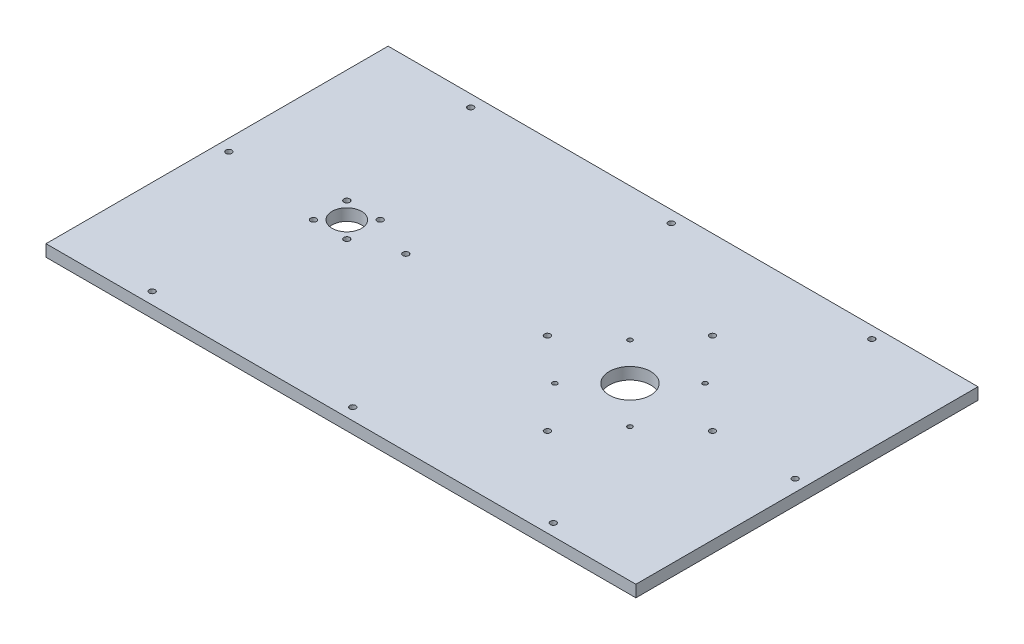
from build123d import *

# Parameters (mm, degrees)
SKETCH1_W           = 500
SKETCH1_H           = 290
SKETCH1_R           = 2.5
SKETCH1_R_2         = 17.5
SKETCH1_R_3         = 12.5
SKETCH1_R_4         = 2
BOSS_EXTRUDE1_DEPTH = 10


with BuildPart() as part:
    # Sketch1 → Boss-Extrude1 (new body)
    with BuildSketch(Plane(origin=(0, 0, 0), x_dir=(1, 0, 0), z_dir=(0, 1, 0))):
        Rectangle(SKETCH1_W, SKETCH1_H)
        with Locations((-240, 0)):
            Circle(SKETCH1_R, mode=Mode.SUBTRACT)
        with Locations((-90, 0)):
            Circle(SKETCH1_R, mode=Mode.SUBTRACT)
        with Locations((-170, -135)):
            Circle(SKETCH1_R, mode=Mode.SUBTRACT)
        with Locations((-170, 135)):
            Circle(SKETCH1_R, mode=Mode.SUBTRACT)
        with Locations((170, 135)):
            Circle(SKETCH1_R, mode=Mode.SUBTRACT)
        with Locations((240, 0)):
            Circle(SKETCH1_R, mode=Mode.SUBTRACT)
        with Locations((170, -135)):
            Circle(SKETCH1_R, mode=Mode.SUBTRACT)
        with Locations((0, 135)):
            Circle(SKETCH1_R, mode=Mode.SUBTRACT)
        with Locations((0, -135)):
            Circle(SKETCH1_R, mode=Mode.SUBTRACT)
        with Locations((100, 0)):
            Circle(SKETCH1_R_2, mode=Mode.SUBTRACT)
        with Locations((-140, 0)):
            Circle(SKETCH1_R_3, mode=Mode.SUBTRACT)
        with Locations((-125.857864376, 14.142135624)):
            Circle(SKETCH1_R, mode=Mode.SUBTRACT)
        with Locations((-125.857864376, -14.142135624)):
            Circle(SKETCH1_R, mode=Mode.SUBTRACT)
        with Locations((-154.142135624, -14.142135624)):
            Circle(SKETCH1_R, mode=Mode.SUBTRACT)
        with Locations((-154.142135624, 14.142135624)):
            Circle(SKETCH1_R, mode=Mode.SUBTRACT)
        with Locations((170, 0)):
            Circle(SKETCH1_R, mode=Mode.SUBTRACT)
        with Locations((131.819805153, 31.819805153)):
            Circle(SKETCH1_R_4, mode=Mode.SUBTRACT)
        with Locations((100, -70)):
            Circle(SKETCH1_R, mode=Mode.SUBTRACT)
        with Locations((30, 0)):
            Circle(SKETCH1_R, mode=Mode.SUBTRACT)
        with Locations((100, 70)):
            Circle(SKETCH1_R, mode=Mode.SUBTRACT)
        with Locations((131.819805153, -31.819805153)):
            Circle(SKETCH1_R_4, mode=Mode.SUBTRACT)
        with Locations((68.180194847, -31.819805153)):
            Circle(SKETCH1_R_4, mode=Mode.SUBTRACT)
        with Locations((68.180194847, 31.819805153)):
            Circle(SKETCH1_R_4, mode=Mode.SUBTRACT)
    extrude(amount=BOSS_EXTRUDE1_DEPTH)


solid = part.part
